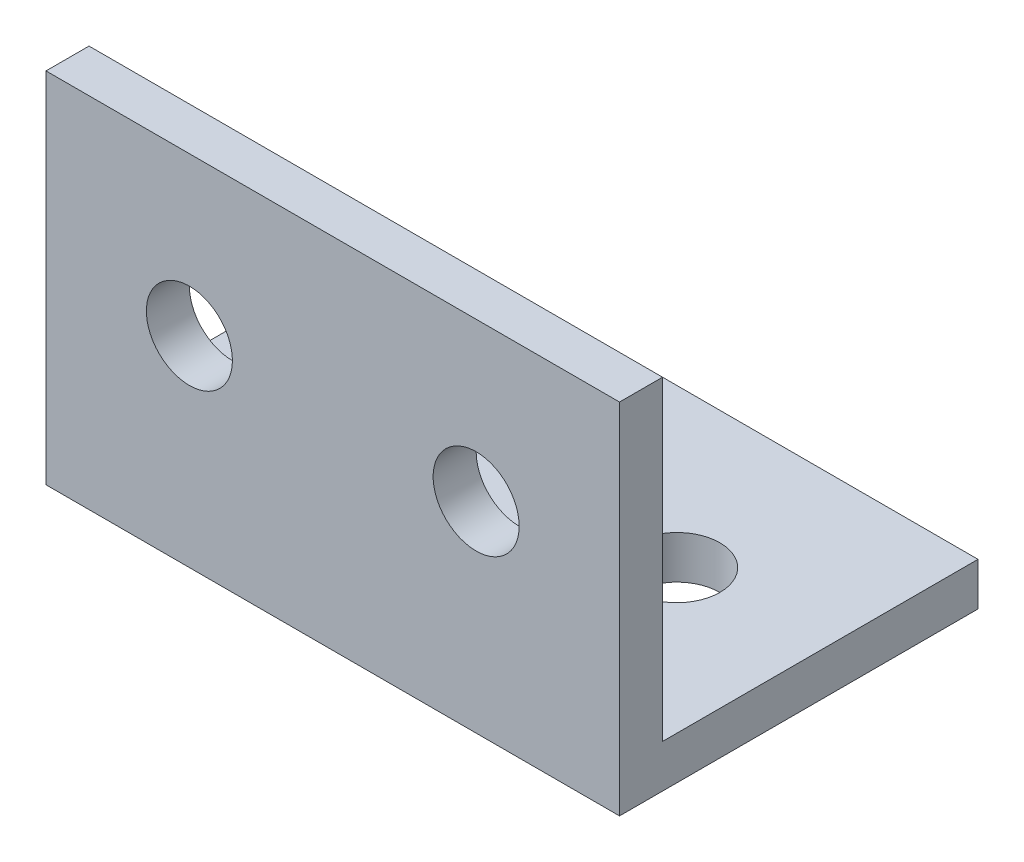
from build123d import *

# Parameters (mm, degrees)
EXTRUDE_1_DEPTH     = 40
SKETCH_2_R          = 3
CUT_EXTRUDE_1_DEPTH = 10
SKETCH_3_R          = 3
CUT_EXTRUDE_2_DEPTH = 10


with BuildPart() as part:
    # Эскиз1 → Вытянуть-Тонкостенный1 (new body)
    with BuildSketch(Plane(origin=(0, 0, 0), x_dir=(0, 0, -1), z_dir=(1, 0, 0))):
        Polygon((25, 0), (0, 0), (0, 25), (3, 25), (3, 3), (25, 3), align=None)
    extrude(amount=EXTRUDE_1_DEPTH)

    # Эскиз2 → Вырез-Вытянуть1 (cut)
    with BuildSketch(Plane.XZ):
        with Locations((10, -14)):
            Circle(SKETCH_2_R)
        with Locations((30, -14)):
            Circle(SKETCH_2_R)
    extrude(amount=-CUT_EXTRUDE_1_DEPTH, mode=Mode.SUBTRACT)

    # Эскиз3 → Вырез-Вытянуть2 (cut)
    with BuildSketch(Plane.XY):
        with Locations((10, 14)):
            Circle(SKETCH_3_R)
        with Locations((30, 14)):
            Circle(SKETCH_3_R)
    extrude(amount=-CUT_EXTRUDE_2_DEPTH, mode=Mode.SUBTRACT)


solid = part.part
